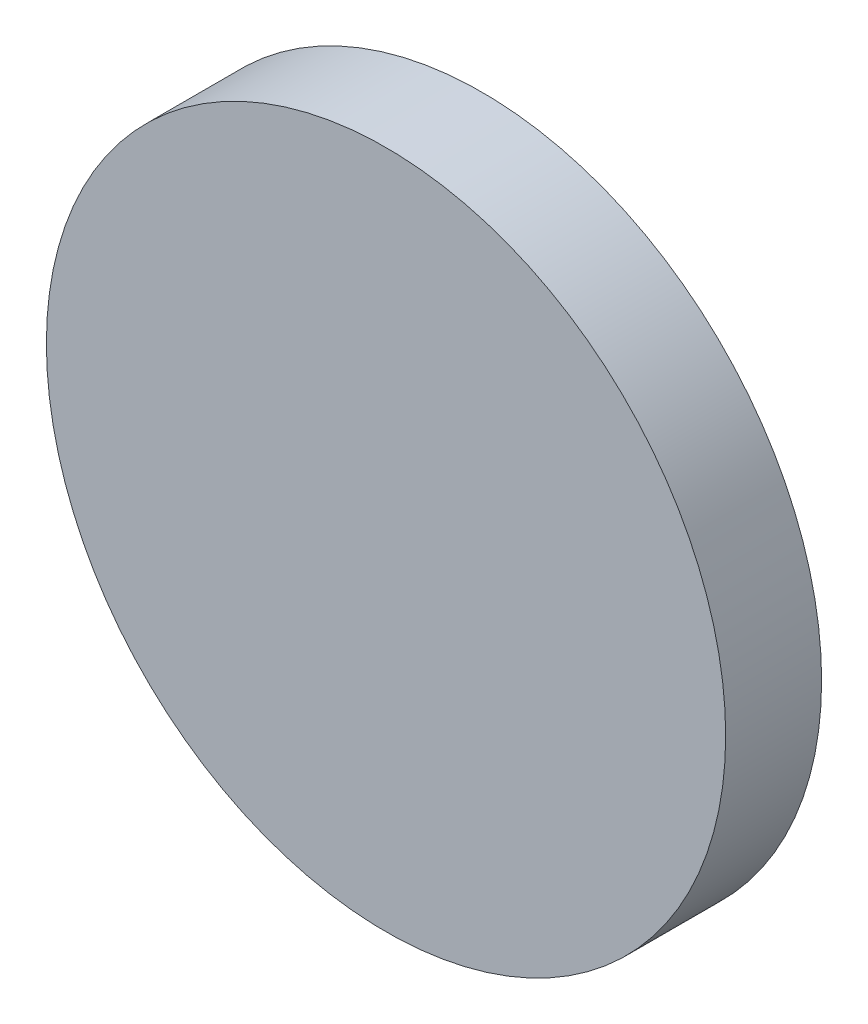
from build123d import *

# Parameters (mm, degrees)
CROQUIS1_R              = 3.54
SALIENTE_EXTRUIR1_DEPTH = 1


with BuildPart() as part:
    # Croquis1 → Saliente-Extruir1 (new body)
    with BuildSketch(Plane.XY):
        Circle(CROQUIS1_R)
    extrude(amount=SALIENTE_EXTRUIR1_DEPTH)


solid = part.part
